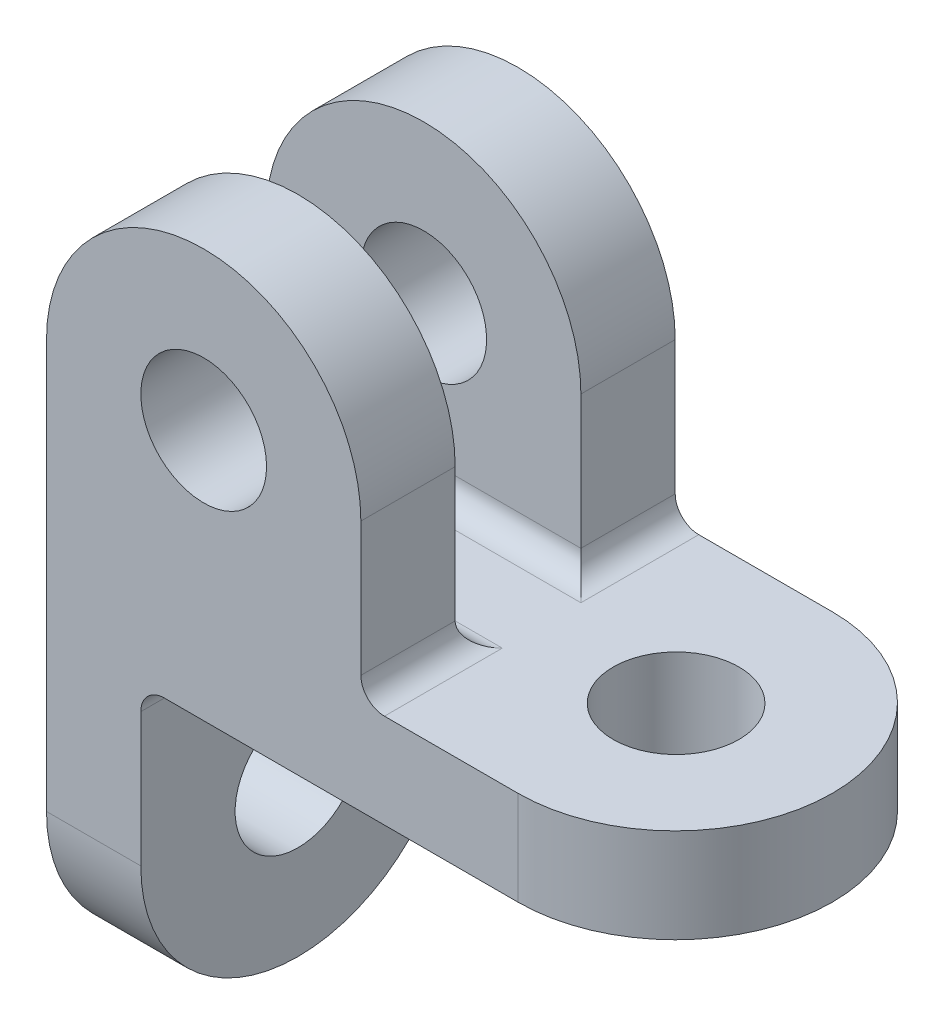
from build123d import *

# Parameters (mm, degrees)
BOSS_EXTRUDE1_DEPTH  = 12
BOSS_EXTRUDE11_DEPTH = 12
BOSS_EXTRUDE12_DEPTH = 12
BOSS_EXTRUDE13_DEPTH = 12
SKETCH8_R            = 8
CUT_EXTRUDE1_DEPTH   = 128
SKETCH9_R            = 8
CUT_EXTRUDE2_DEPTH   = 128
SKETCH10_R           = 8
CUT_EXTRUDE4_DEPTH   = 128
FILLET4_R            = 3


with BuildPart() as part:
    # Sketch2 → Boss-Extrude1 (new body)
    with BuildSketch(Plane(origin=(0, 0, 0), x_dir=(1, 0, 0), z_dir=(0, 1, 0))):
        with BuildLine():
            Line((-30, 20), (30, 20))
            ThreePointArc((30, 20), (50, 0), (30, -20))
            Line((30, -20), (-30, -20))
            Line((-30, -20), (-30, 20))
        make_face()
    extrude(amount=BOSS_EXTRUDE1_DEPTH)

    # Sketch3 → Boss-Extrude11 (add)
    with BuildSketch(Plane.XY.offset(20)):
        with BuildLine():
            ThreePointArc((10, 32), (-10, 52), (-30, 32))
            Line((-30, 32), (10, 32))
        make_face()
        with BuildLine():
            ThreePointArc((-30, 32), (-24.142135624, 17.857864376), (-10, 12))
            ThreePointArc((-10, 12), (4.142135624, 17.857864376), (10, 32))
            Line((10, 32), (-30, 32))
        make_face()
        with BuildLine():
            Line((-30, 32), (-30, 12))
            Line((-30, 12), (-10, 12))
            ThreePointArc((-10, 12), (-24.142135624, 17.857864376), (-30, 32))
        make_face()
        with BuildLine():
            ThreePointArc((10, 32), (4.142135624, 17.857864376), (-10, 12))
            Line((-10, 12), (10, 12))
            Line((10, 12), (10, 32))
        make_face()
    extrude(amount=-BOSS_EXTRUDE11_DEPTH)

    # Sketch5 → Boss-Extrude12 (add)
    with BuildSketch(Plane(origin=(0, 0, -20), x_dir=(-1, 0, 0), z_dir=(0, 0, -1))):
        with BuildLine():
            Line((10, 12), (30, 12))
            Line((30, 12), (30, 32))
            ThreePointArc((30, 32), (24.142135624, 17.857864376), (10, 12))
        make_face()
        with BuildLine():
            Line((-10, 12), (10, 12))
            ThreePointArc((10, 12), (-4.142135624, 17.857864376), (-10, 32))
            Line((-10, 32), (-10, 12))
        make_face()
        with BuildLine():
            ThreePointArc((-10, 32), (-4.142135624, 17.857864376), (10, 12))
            ThreePointArc((10, 12), (24.142135624, 17.857864376), (30, 32))
            Line((30, 32), (-10, 32))
        make_face()
        with BuildLine():
            Line((-10, 32), (30, 32))
            ThreePointArc((30, 32), (10, 52), (-10, 32))
        make_face()
    extrude(amount=-BOSS_EXTRUDE12_DEPTH)

    # Sketch6 → Boss-Extrude13 (add)
    with BuildSketch(Plane.ZY.offset(30)):
        with BuildLine():
            Line((20, 0), (0, 0))
            ThreePointArc((0, 0), (14.142135624, -5.857864376), (20, -20))
            Line((20, -20), (20, 0))
        make_face()
        with BuildLine():
            Line((0, 0), (-20, 0))
            Line((-20, 0), (-20, -20))
            ThreePointArc((-20, -20), (-14.142135624, -5.857864376), (0, 0))
        make_face()
        with BuildLine():
            ThreePointArc((20, -20), (14.142135624, -5.857864376), (0, 0))
            ThreePointArc((0, 0), (-14.142135624, -5.857864376), (-20, -20))
            Line((-20, -20), (20, -20))
        make_face()
        with BuildLine():
            Line((20, -20), (-20, -20))
            ThreePointArc((-20, -20), (0, -40), (20, -20))
        make_face()
    extrude(amount=-BOSS_EXTRUDE13_DEPTH)

    # Sketch8 → Cut-Extrude1 (cut)
    with BuildSketch(Plane.XY.offset(20)):
        with Locations((-10, 32)):
            Circle(SKETCH8_R)
    extrude(amount=-CUT_EXTRUDE1_DEPTH, mode=Mode.SUBTRACT)

    # Sketch9 → Cut-Extrude2 (cut)
    with BuildSketch(Plane(origin=(0, 12, 0), x_dir=(1, 0, 0), z_dir=(0, 1, 0))):
        with Locations((30.130515164, -0.017591691)):
            Circle(SKETCH9_R)
    extrude(amount=-CUT_EXTRUDE2_DEPTH, mode=Mode.SUBTRACT)

    # Sketch10 → Cut-Extrude4 (cut)
    with BuildSketch(Plane(origin=(-18, 0, 0), x_dir=(0, 0, -1), z_dir=(1, 0, 0))):
        with Locations((0, -20)):
            Circle(SKETCH10_R)
    extrude(amount=-CUT_EXTRUDE4_DEPTH, mode=Mode.SUBTRACT)

    # Fillet4
    fillet4_edges = [part.edges().sort_by_distance(p)[0] for p in [
        (10, 12, 14),
        (-10, 12, 8),
        (10, 12, -14),
        (-10, 12, -8),
        (-18, 0, 0),
    ]]
    fillet(fillet4_edges, radius=FILLET4_R)


solid = part.part
